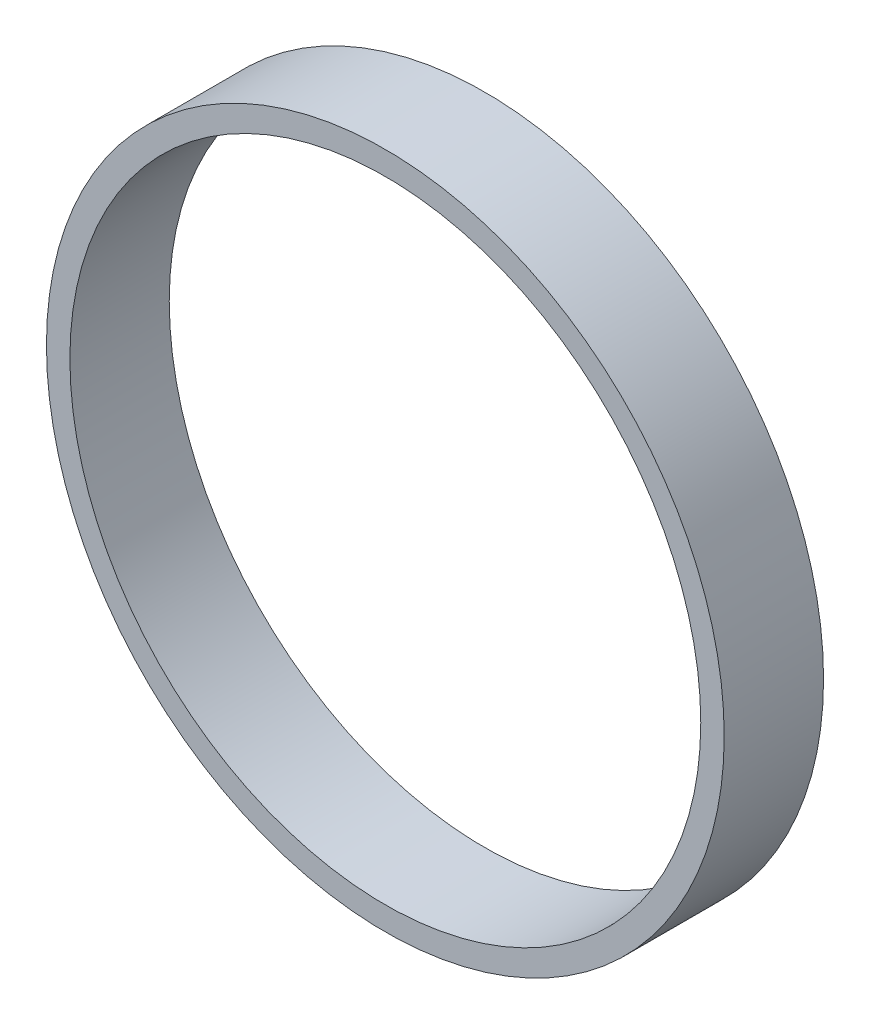
from build123d import *

# Parameters (mm, degrees)
SKETCH1_R           = 34.11
SKETCH1_R_2         = 31.75
BOSS_EXTRUDE1_DEPTH = 10


with BuildPart() as part:
    # Sketch1 → Boss-Extrude1 (new body)
    with BuildSketch(Plane.XY):
        Circle(SKETCH1_R)
        Circle(SKETCH1_R_2, mode=Mode.SUBTRACT)
    extrude(amount=BOSS_EXTRUDE1_DEPTH)


solid = part.part
